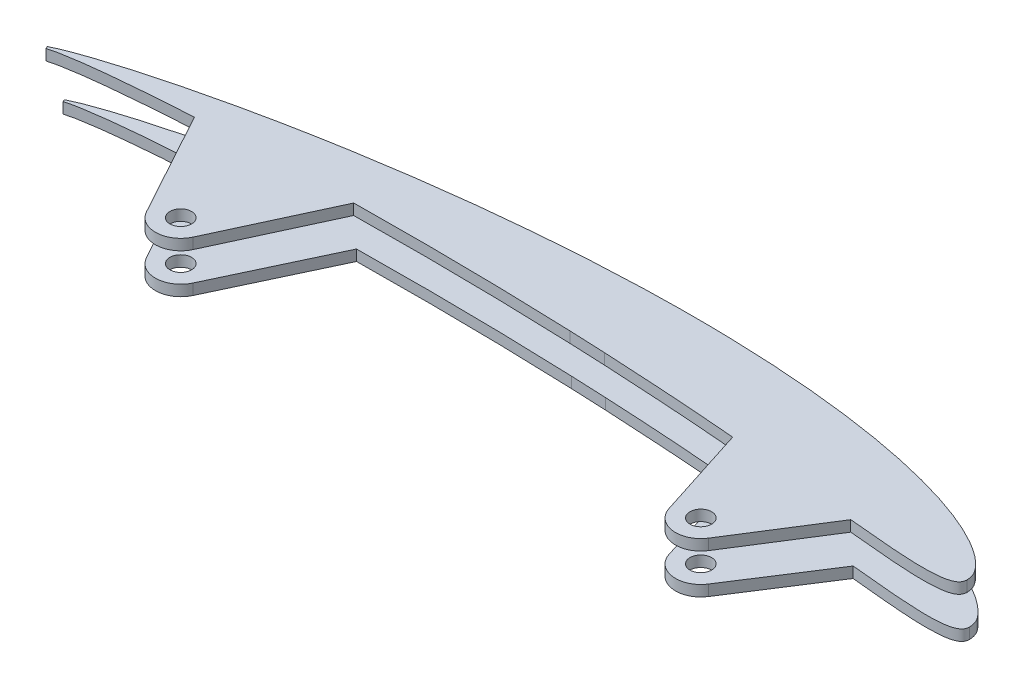
from build123d import *

# Parameters (mm, degrees)
SZKIC5_R                    = 3
DODANIE_WYCI_GNI_CIE1_DEPTH = 3
SZKIC6_R                    = 3
DODANIE_WYCI_GNI_CIE2_DEPTH = 3


with BuildPart() as part:
    # Szkic5 → Dodanie-wyciągnięcie1 (new body)
    with BuildSketch(Plane(origin=(0, 238, 0), x_dir=(1, 0, 0), z_dir=(0, 1, 0))):
        with BuildLine():
            Line((-217.621483836, -264.229627813), (-217.336994821, -264.87228097))
            add(Edge.make_bspline(
                [(-217.336994821, -264.87228097), (-216.524251746, -264.64941213), (-215.708414587, -264.44009422), (-214.060701234, -264.091703348), (-213.229095975, -263.95042135), (-210.734466698, -263.544586682), (-209.068304452, -263.298661057), (-205.727674147, -262.87331659), (-204.053883814, -262.688471023), (-200.704198463, -262.335632645), (-199.027655474, -262.171215157), (-193.994257482, -261.719774509), (-190.635355721, -261.465840041), (-184.960732923, -261.077127862), (-182.645707604, -260.932445278), (-180.32988849, -260.799063872)],
                knots=[0, 0, 0, 0, 0.0625, 0.0625, 0.125, 0.125, 0.25, 0.25, 0.375, 0.375, 0.5, 0.5, 0.75, 0.75, 0.92214748, 0.92214748, 0.92214748, 0.92214748], degree=3))
            Line((-180.32988849, -260.799063872), (-164.276497186, -290.144205364))
            ThreePointArc((-164.276497186, -290.144205364), (-157.899417061, -293.78069291), (-151.781835373, -289.722813305))
            Line((-151.781835373, -289.722813305), (-137.728906741, -259.334339822))
            add(Edge.make_bspline(
                [(-137.728906741, -259.334339822), (-132.548108585, -259.259957785), (-127.367426672, -259.220604013), (-114.686266361, -259.207555796), (-107.185914373, -259.271953011), (-92.185702095, -259.548912987), (-84.685072734, -259.761345903), (-77.187477809, -260.052501815)],
                knots=[0.32732798, 0.32732798, 0.32732798, 0.32732798, 0.5, 0.5, 0.75, 0.75, 1, 1, 1, 1], degree=3))
            Line((-77.187477809, -260.052501815), (-67.187477851, -260.487776944))
            add(Edge.make_bspline(
                [(-67.187477851, -260.487776944), (-58.32766484, -260.915181374), (-49.472971628, -261.455568777), (-36.811235704, -262.38407526), (-32.996403084, -262.682920862), (-29.183533603, -263.003801126)],
                knots=[0, 0, 0, 0, 0.25, 0.25, 0.357869734, 0.357869734, 0.357869734, 0.357869734], degree=3))
            Line((-29.183533603, -263.003801126), (-20.885838964, -288.919212053))
            ThreePointArc((-20.885838964, -288.919212053), (-15.10720147, -293.728120595), (-8.304342773, -290.528219626))
            Line((-8.304342773, -290.528219626), (6.937299884, -266.446117532))
            add(Edge.make_bspline(
                [(6.937299884, -266.446117532), (8.743620815, -266.62254106), (10.550231116, -266.795716646), (14.564818443, -267.168384755), (16.773153564, -267.363411544), (20.089312757, -267.609922909), (21.19536559, -267.684816125), (23.408308538, -267.817850843), (24.515163217, -267.876696188), (26.730636503, -267.959071889), (27.839248431, -267.981090967), (29.501605944, -267.961470678), (30.055935582, -267.946372101), (31.163310398, -267.895568492), (31.716349127, -267.860380396), (32.820112211, -267.755088467), (33.370294556, -267.685569662), (34.185351903, -267.529765615), (34.455447712, -267.469072407), (34.991451854, -267.324618872), (35.256616721, -267.24182603), (35.772971322, -267.043663657), (36.026317432, -266.927931118), (36.385529035, -266.716197032), (36.500736955, -266.639417318), (36.718928374, -266.469119692), (36.822857912, -266.374625212), (37.009414856, -266.168580037), (37.091759033, -266.057703984), (37.231498063, -265.818032231), (37.288842861, -265.688986423), (37.418790516, -265.294501953), (37.453207535, -265.014441354), (37.457874933, -264.734992214)],
                knots=[0.698836384, 0.698836384, 0.698836384, 0.698836384, 0.75, 0.75, 0.8125, 0.8125, 0.84375, 0.84375, 0.875, 0.875, 0.90625, 0.90625, 0.921875, 0.921875, 0.9375, 0.9375, 0.953125, 0.953125, 0.9609375, 0.9609375, 0.96875, 0.96875, 0.9765625, 0.9765625, 0.98046875, 0.98046875, 0.984375, 0.984375, 0.98828125, 0.98828125, 0.9921875, 0.9921875, 1, 1, 1, 1], degree=3))
            add(Edge.make_bspline(
                [(37.457874933, -264.734992214), (37.447307587, -264.483392729), (37.41848087, -264.23406027), (37.33363794, -263.738771113), (37.27750378, -263.493240453), (37.133832229, -263.012703951), (37.045593151, -262.776093324), (36.837114669, -262.319794772), (36.717139813, -262.099591951), (36.584242776, -261.885914808)],
                knots=[0, 0, 0, 0, 0.25, 0.25, 0.5, 0.5, 0.75, 0.75, 1, 1, 1, 1], degree=3))
            add(Edge.make_bspline(
                [(36.584242776, -261.885914808), (36.27860279, -261.394461341), (35.919039572, -260.952691489), (35.157723901, -260.108023965), (34.754749419, -259.706252242), (33.920624453, -258.928669512), (33.486868131, -258.552907315), (32.599935756, -257.83955132), (32.14623595, -257.50042651), (30.759380309, -256.527230368), (29.80124069, -255.936012406), (27.847669337, -254.817541682), (26.85134856, -254.291813847), (24.827758173, -253.293443084), (23.799699869, -252.821214557), (21.719003409, -251.922804441), (20.670860128, -251.498241031), (17.507840792, -250.283315752), (15.374688976, -249.550727069), (11.071792042, -248.201228132), (8.901838928, -247.584975401), (4.532467444, -246.445615254), (2.33083291, -245.922261993), (-4.291115044, -244.47467329), (-8.729992949, -243.670655148), (-17.64438867, -242.305980393), (-22.120060781, -241.746348593), (-31.101669829, -240.828103351), (-35.608641857, -240.469929105), (-44.621387532, -239.928777021), (-49.130860769, -239.74555865), (-58.155230695, -239.531934505), (-62.670117957, -239.50126313), (-67.187477851, -239.540261269)],
                knots=[0, 0, 0, 0, 0.015625, 0.015625, 0.03125, 0.03125, 0.046875, 0.046875, 0.0625, 0.0625, 0.09375, 0.09375, 0.125, 0.125, 0.15625, 0.15625, 0.1875, 0.1875, 0.25, 0.25, 0.3125, 0.3125, 0.375, 0.375, 0.5, 0.5, 0.625, 0.625, 0.75, 0.75, 0.875, 0.875, 1, 1, 1, 1], degree=3))
            Line((-67.187477851, -239.540261269), (-77.187477809, -239.737805085))
            add(Edge.make_bspline(
                [(-77.187477809, -239.737805085), (-80.96883775, -239.853554602), (-84.748045673, -240.014473104), (-92.302382502, -240.421925103), (-96.078141665, -240.668566402), (-107.387458792, -241.52948044), (-114.906920153, -242.264039468), (-129.908697906, -244.030223333), (-137.391055865, -245.061515738), (-152.319179963, -247.416742581), (-159.768554901, -248.739980764), (-167.187460508, -250.22154165)],
                knots=[0, 0, 0, 0, 0.125, 0.125, 0.25, 0.25, 0.5, 0.5, 0.75, 0.75, 1, 1, 1, 1], degree=3))
            Line((-167.187460508, -250.22154165), (-177.187477809, -252.321954819))
            add(Edge.make_bspline(
                [(-177.187477809, -252.321954819), (-180.624552007, -253.08048169), (-184.052746461, -253.875929186), (-190.887399363, -255.557199196), (-194.296565633, -256.438692834), (-199.37903267, -257.852994817), (-201.067813223, -258.340705566), (-204.434624431, -259.348679498), (-206.114020702, -259.864807376), (-209.451561178, -260.961417835), (-211.109722558, -261.541848411), (-213.582926098, -262.45500522), (-214.403746995, -262.770232499), (-216.02462962, -263.463549194), (-216.824492989, -263.842239273), (-217.621483836, -264.229627813)],
                knots=[0, 0, 0, 0, 0.25, 0.25, 0.5, 0.5, 0.625, 0.625, 0.75, 0.75, 0.875, 0.875, 0.9375, 0.9375, 1, 1, 1, 1], degree=3))
        make_face()
        with Locations((-14.2192257, -286.784670513)):
            Circle(SZKIC5_R, mode=Mode.SUBTRACT)
        with Locations((-158.135363286, -286.784670513)):
            Circle(SZKIC5_R, mode=Mode.SUBTRACT)
    extrude(amount=DODANIE_WYCI_GNI_CIE1_DEPTH)


with BuildPart() as body_2:
    # Szkic6 → Dodanie-wyciągnięcie2 (new body)
    with BuildSketch(Plane.XZ.offset(-229.999999684)):
        with BuildLine():
            Line((-20.891500237, 288.901449317), (-29.215786562, 262.662560496))
            add(Edge.make_bspline(
                [(-29.215786562, 262.662560496), (-32.970793032, 262.343169873), (-36.727483431, 262.045831102), (-49.377539494, 261.106282985), (-58.278097232, 260.558257239), (-67.187477852, 260.125771269)],
                knots=[0.644340635, 0.644340635, 0.644340635, 0.644340635, 0.75, 0.75, 1, 1, 1, 1], degree=3))
            Line((-67.187477852, 260.125771269), (-77.100180151, 259.691579953))
            add(Edge.make_bspline(
                [(-77.100180151, 259.691579953), (-92.109908332, 259.104983769), (-107.131065459, 258.833934183), (-127.204829254, 258.859690732), (-132.262623565, 258.899187952), (-137.320223468, 258.972831386)],
                knots=[0, 0, 0, 0, 0.5, 0.5, 0.66842221, 0.66842221, 0.66842221, 0.66842221], degree=3))
            Line((-137.320223468, 258.972831386), (-151.800908071, 289.763710144))
            ThreePointArc((-151.800908071, 289.763710144), (-157.909668811, 293.781031139), (-164.264647603, 290.165775918))
            Line((-164.264647603, 290.165775918), (-180.616624417, 260.522832843))
            add(Edge.make_bspline(
                [(-180.616624417, 260.522832843), (-182.493301494, 260.63836347), (-184.369413876, 260.762388462), (-189.262195351, 261.10981356), (-192.277944307, 261.345744825), (-196.796312793, 261.767892425), (-198.301399641, 261.919649362), (-201.30843242, 262.241113307), (-202.810410036, 262.412205749), (-205.057459681, 262.708681739), (-205.80539464, 262.814789342), (-207.299730516, 263.037333174), (-208.046317133, 263.152519085), (-209.537277472, 263.397790206), (-210.281526427, 263.528715457), (-211.761514774, 263.847860353), (-212.497234354, 264.036213388), (-213.231366735, 264.235252934)],
                knots=[0.094621775, 0.094621775, 0.094621775, 0.094621775, 0.25, 0.25, 0.5, 0.5, 0.625, 0.625, 0.75, 0.75, 0.8125, 0.8125, 0.875, 0.875, 0.9375, 0.9375, 1, 1, 1, 1], degree=3))
            Line((-213.231366735, 264.235252934), (-213.511668484, 263.601049744))
            add(Edge.make_bspline(
                [(-213.511668484, 263.601049744), (-212.795694173, 263.256191843), (-212.077427616, 262.917799439), (-210.623241682, 262.290806268), (-209.887104074, 262.002821034), (-208.405913358, 261.451997661), (-207.661990376, 261.185971885), (-206.171386796, 260.661698473), (-205.424002038, 260.405436996), (-203.174660884, 259.656923904), (-201.665215498, 259.185795767), (-198.63604595, 258.27253185), (-197.116828704, 257.827952687), (-192.549099551, 256.536908745), (-189.489642337, 255.732197165), (-183.352251843, 254.195085169), (-180.274129794, 253.46342355), (-177.187477809, 252.765146182)],
                knots=[0, 0, 0, 0, 0.0625, 0.0625, 0.125, 0.125, 0.1875, 0.1875, 0.25, 0.25, 0.375, 0.375, 0.5, 0.5, 0.75, 0.75, 1, 1, 1, 1], degree=3))
            Line((-177.187477809, 252.765146182), (-167.187460508, 250.615415308))
            add(Edge.make_bspline(
                [(-167.187460508, 250.615415308), (-163.4762283, 249.857598754), (-159.757194432, 249.141305806), (-152.304641953, 247.785813577), (-148.570544679, 247.146649381), (-137.35819434, 245.341673931), (-129.866595376, 244.287675975), (-114.849893841, 242.479267101), (-107.324773255, 241.725017275), (-96.01003893, 240.835552658), (-92.233936919, 240.579516888), (-84.672146707, 240.153164435), (-80.886594095, 239.982885941), (-77.100180151, 239.858046276)],
                knots=[0, 0, 0, 0, 0.125, 0.125, 0.25, 0.25, 0.5, 0.5, 0.75, 0.75, 0.875, 0.875, 1, 1, 1, 1], degree=3))
            Line((-77.100180151, 239.858046276), (-67.187477851, 239.637502802))
            add(Edge.make_bspline(
                [(-67.187477851, 239.637502802), (-62.642451296, 239.586329504), (-58.098009464, 239.605559168), (-49.01040898, 239.798518641), (-44.468663763, 239.972129202), (-35.401774311, 240.495112022), (-30.87506353, 240.844371603), (-24.096773442, 241.521746819), (-21.839319637, 241.773296055), (-17.328743108, 242.332844511), (-15.075802975, 242.64091678), (-8.337413379, 243.657912381), (-3.867987376, 244.458271394), (2.791147733, 245.899977903), (5.004501136, 246.421357183), (9.40768675, 247.56011241), (11.594338971, 248.176431419), (15.930101914, 249.527019984), (18.079400287, 250.260699966), (21.266132664, 251.478145245), (22.32302148, 251.904067878), (24.41018445, 252.80048995), (25.441413746, 253.271581574), (27.473820784, 254.269430856), (28.475275307, 254.795675816), (30.441229829, 255.916618489), (31.406623556, 256.509660702), (32.806869488, 257.48784913), (33.266264909, 257.829966961), (34.16105315, 258.547953497), (34.593068233, 258.921837868), (35.42671254, 259.699028412), (35.829678651, 260.101040113), (36.591931528, 260.947357038), (36.952564828, 261.390358448), (37.258921121, 261.885914808)],
                knots=[0, 0, 0, 0, 0.125, 0.125, 0.25, 0.25, 0.375, 0.375, 0.4375, 0.4375, 0.5, 0.5, 0.625, 0.625, 0.6875, 0.6875, 0.75, 0.75, 0.8125, 0.8125, 0.84375, 0.84375, 0.875, 0.875, 0.90625, 0.90625, 0.9375, 0.9375, 0.953125, 0.953125, 0.96875, 0.96875, 0.984375, 0.984375, 1, 1, 1, 1], degree=3))
            add(Edge.make_bspline(
                [(37.258921121, 261.885914808), (37.389123894, 262.096517164), (37.506666282, 262.313616063), (37.710799842, 262.763696153), (37.79682304, 262.996395066), (37.936864263, 263.469528567), (37.991492793, 263.711593238), (38.073542365, 264.19865361), (38.101232558, 264.443916104), (38.110958839, 264.691512304)],
                knots=[0, 0, 0, 0, 0.25, 0.25, 0.5, 0.5, 0.75, 0.75, 1, 1, 1, 1], degree=3))
            add(Edge.make_bspline(
                [(38.110958839, 264.691512304), (38.105450454, 264.97503637), (38.070240518, 265.252920472), (37.932512112, 265.653622587), (37.871723379, 265.784278977), (37.724636177, 266.024446344), (37.637330167, 266.1363289), (37.341926894, 266.445477772), (37.111833277, 266.607877539), (36.61546919, 266.88499914), (36.357859291, 266.996332826), (35.832100479, 267.186761327), (35.563828865, 267.265915117), (35.020312101, 267.403452327), (34.743942023, 267.461240628), (33.914355815, 267.607513604), (33.360047105, 267.670660169), (32.250272997, 267.765181607), (31.694784148, 267.795912326), (30.58310942, 267.838227899), (30.026899636, 267.849156103), (28.357334297, 267.856231238), (27.243023643, 267.826143683), (25.013085827, 267.729806995), (23.899368809, 267.66525799), (21.673545947, 267.521287373), (20.561407664, 267.440878272), (17.227012665, 267.177643833), (15.006857619, 266.971919857), (10.982806472, 266.584371065), (9.178642012, 266.405470132), (7.374746204, 266.223642119)],
                knots=[0, 0, 0, 0, 0.0078125, 0.0078125, 0.01171875, 0.01171875, 0.015625, 0.015625, 0.0234375, 0.0234375, 0.03125, 0.03125, 0.0390625, 0.0390625, 0.046875, 0.046875, 0.0625, 0.0625, 0.078125, 0.078125, 0.09375, 0.09375, 0.125, 0.125, 0.15625, 0.15625, 0.1875, 0.1875, 0.25, 0.25, 0.300819406, 0.300819406, 0.300819406, 0.300819406], degree=3))
            Line((7.374746204, 266.223642119), (-8.33697323, 290.579285893))
            ThreePointArc((-8.33697323, 290.579285893), (-15.146489207, 293.722983161), (-20.891500237, 288.901449317))
        make_face()
        with Locations((-14.2192257, 286.784670513)):
            Circle(SZKIC6_R, mode=Mode.SUBTRACT)
        with Locations((-158.135363286, 286.784670513)):
            Circle(SZKIC6_R, mode=Mode.SUBTRACT)
    extrude(amount=DODANIE_WYCI_GNI_CIE2_DEPTH)


solid = Compound([part.part, body_2.part])
